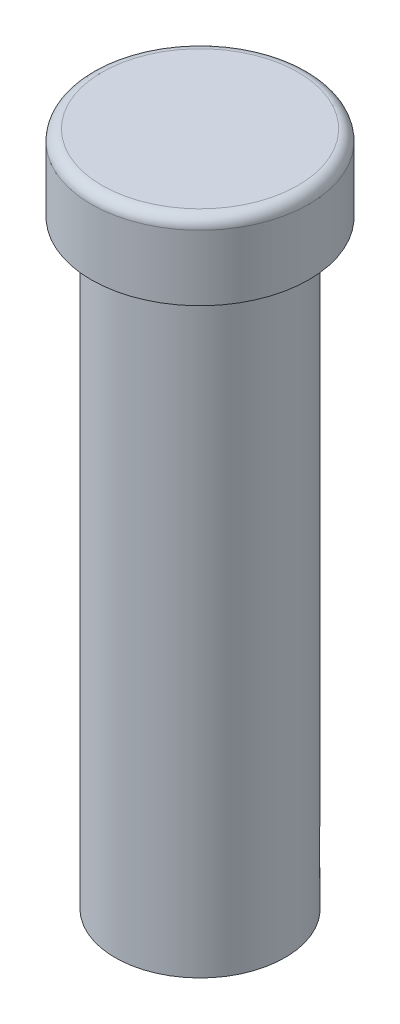
from build123d import *

# Parameters (mm, degrees)
SKETCH1_R           = 12.7
BOSS_EXTRUDE1_DEPTH = 8.89
SKETCH2_R           = 9.906
BOSS_EXTRUDE2_DEPTH = 69.85
FILLET2_R           = 1.27
CUT_EXTRUDE1_START  = -8.89
SKETCH5_W           = 28.368479266
SKETCH5_H           = 5.191734841
CUT_EXTRUDE1_DEPTH  = 69.85


with BuildPart() as part:
    # Sketch1 → Boss-Extrude1 (new body)
    with BuildSketch(Plane(origin=(0, 0, 0), x_dir=(1, 0, 0), z_dir=(0, 1, 0))):
        Circle(SKETCH1_R)
    extrude(amount=BOSS_EXTRUDE1_DEPTH)

    # Sketch2 → Boss-Extrude2 (add)
    with BuildSketch(Plane.XZ):
        Circle(SKETCH2_R)
    extrude(amount=BOSS_EXTRUDE2_DEPTH)

    # Fillet2
    fillet2_edges = [part.edges().sort_by_distance(p)[0] for p in [
        (-12.7, 8.89, 0),
    ]]
    fillet(fillet2_edges, radius=FILLET2_R)

    # Sketch5 → Cut-Extrude1 (cut)
    with BuildSketch(Plane.XY.offset(2.54).offset(CUT_EXTRUDE1_START)):
        with Locations((1.524929724, -63.573523151)):
            Rectangle(SKETCH5_W, SKETCH5_H)
    extrude(amount=-CUT_EXTRUDE1_DEPTH, mode=Mode.SUBTRACT)


solid = part.part
